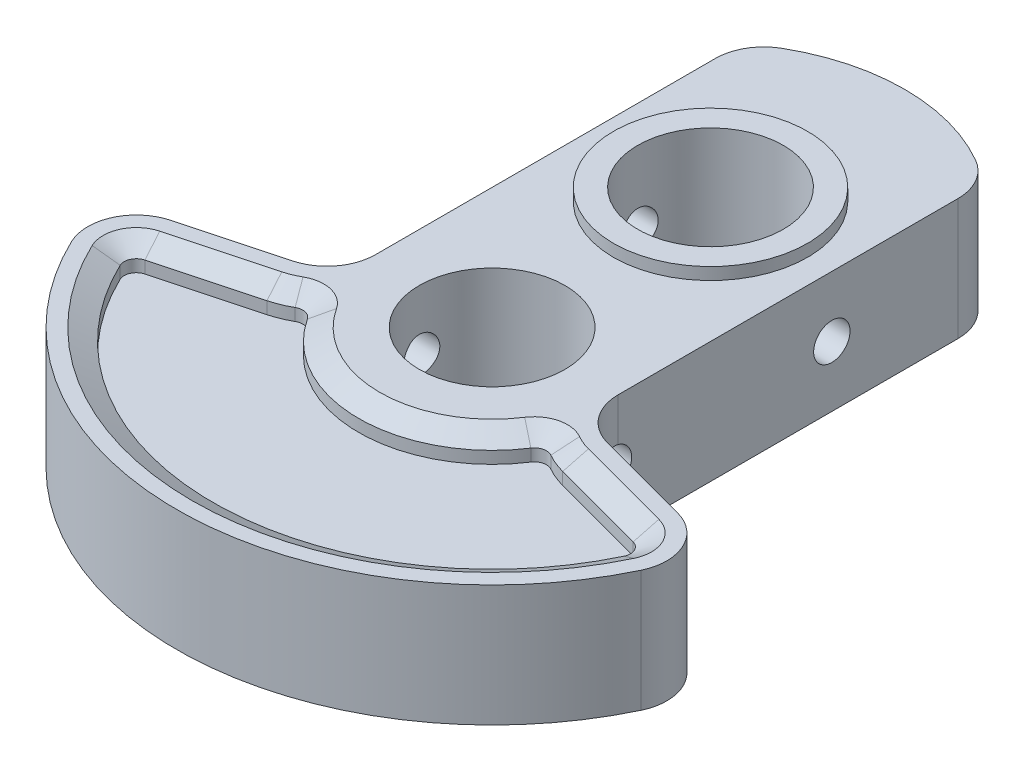
from build123d import *
from OCP.BRepFilletAPI import BRepFilletAPI_MakeChamfer

# Parameters (mm, degrees)
BOSS_EXTRUDE1_DEPTH       = 5
FILLET1_R                 = 4
SKETCH2_R                 = 8
BOSS_EXTRUDE2_DEPTH       = 1
SKETCH3_R                 = 8
BOSS_EXTRUDE3_DEPTH       = 1
SKETCH4_R                 = 6
CUT_EXTRUDE1_DEPTH        = 44.235891121
CUT_EXTRUDE2_DEPTH        = 2
CHAMFER1_SIZE             = 1
CHAMFER1_SIZE2            = 1.732050808
CHAMFER1_OF_MIRROR3_SIZE  = 1
CHAMFER1_OF_MIRROR3_SIZE2 = 1.732050808
SKETCH6_R                 = 1.5
CUT_EXTRUDE3_DEPTH        = 42.968348563
CUT_EXTRUDE3_DEPTH_BACK   = 42.968348563


with BuildPart() as part:
    # Sketch1 → Boss-Extrude1 (new, symmetric)
    with BuildSketch(Plane(origin=(0, 0, 0), x_dir=(1, 0, 0), z_dir=(0, 1, 0))):
        with BuildLine():
            Line((-10, 30.489995997), (-10, -2.679491924))
            Line((-10, -2.679491924), (-25.114071484, -6.729295173))
            ThreePointArc((-25.114071484, -6.729295173), (0, -26), (25.114071484, -6.729295173))
            Line((25.114071484, -6.729295173), (10, -2.679491924))
            Line((10, -2.679491924), (10, 30.489995997))
            ThreePointArc((10, 30.489995997), (0, 34), (-10, 30.489995997))
        make_face()
    extrude(amount=BOSS_EXTRUDE1_DEPTH, both=True)

    # Fillet1
    fillet1_edges = [part.edges().sort_by_distance(p)[0] for p in [
        (10, 0, -30.489995997),
        (10, 0, 2.679491924),
        (25.114071484, 0, 6.729295173),
        (-25.114071484, 0, 6.729295173),
        (-10, 0, 2.679491924),
        (-10, 0, -30.489995997),
    ]]
    fillet(fillet1_edges, radius=FILLET1_R)

    # Sketch2 → Boss-Extrude2 (add)
    with BuildSketch(Plane.XZ.offset(5)):
        with Locations(Location((0, 0, 0), (0, 0, 90))):
            Circle(SKETCH2_R)
    extrude(amount=BOSS_EXTRUDE2_DEPTH)

    # Sketch3 → Boss-Extrude3 (add)
    with BuildSketch(Plane(origin=(0, 5, 0), x_dir=(1, 0, 0), z_dir=(0, 1, 0))):
        with Locations(Location((0, 18, 0), (0, 0, 270))):
            Circle(SKETCH3_R)
    extrude(amount=BOSS_EXTRUDE3_DEPTH)

    # Sketch4 → Cut-Extrude1 (cut, through all)
    with BuildSketch(Plane.XZ.offset(6)):
        with Locations(Location((0, 0, 0), (0, 0, 270))):
            Circle(SKETCH4_R)
        with Locations(Location((0, -18, 0), (0, 0, 270))):
            Circle(SKETCH4_R)
    extrude(amount=-CUT_EXTRUDE1_DEPTH, mode=Mode.SUBTRACT)

    # Sketch5 → Cut-Extrude2 (cut)
    with BuildSketch(Plane(origin=(0, 5, 0), x_dir=(1, 0, 0), z_dir=(0, 1, 0))):
        with BuildLine():
            Line((12.188266684, -6.371664756), (20.119713435, -8.496889508))
            ThreePointArc((20.119713435, -8.496889508), (20.768948696, -9.043962883), (20.763662316, -9.892943304))
            ThreePointArc((20.763662316, -9.892943304), (0, -23), (-20.763662316, -9.892943304))
            ThreePointArc((-20.763662316, -9.892943304), (-20.768948696, -9.043962883), (-20.119713435, -8.496889508))
            Line((-20.119713435, -8.496889508), (-12.188266684, -6.371664756))
            ThreePointArc((-12.188266684, -6.371664756), (-11.342355786, -6.086056673), (-10.539679728, -5.695098402))
            ThreePointArc((-10.539679728, -5.695098402), (-9.810114884, -5.592432974), (-9.208235905, -6.017340901))
            ThreePointArc((-9.208235905, -6.017340901), (0, -11), (9.208235905, -6.017340901))
            ThreePointArc((9.208235905, -6.017340901), (9.810114884, -5.592432974), (10.539679728, -5.695098402))
            ThreePointArc((10.539679728, -5.695098402), (11.342355786, -6.086056673), (12.188266684, -6.371664756))
        make_face()
    cut_extrude2 = extrude(amount=-CUT_EXTRUDE2_DEPTH, mode=Mode.SUBTRACT)

    # Chamfer1: one chamfer whose edges measure the first distance from different faces: ONE call of the kernel's chamfer builder (chamfer() names one face for all edges)
    chamfer1_edges_1 = [part.edges().sort_by_distance(p)[0] for p in [
        (9.810114884, 5, 5.592432974),
    ]]
    chamfer1_side_1 = [part.faces().sort_by_distance(p)[0] for p in [
        (9.810114884, 4, 5.592432974),
    ]]
    chamfer1_edges_2 = [part.edges().sort_by_distance(p)[0] for p in [
        (0, 5, 11),
    ]]
    chamfer1_side_2 = [part.faces().sort_by_distance(p)[0] for p in [
        (0, 4, 11),
    ]]
    chamfer1_edges_3 = [part.edges().sort_by_distance(p)[0] for p in [
        (-9.810114884, 5, 5.592432974),
    ]]
    chamfer1_side_3 = [part.faces().sort_by_distance(p)[0] for p in [
        (-9.810114884, 4, 5.592432974),
    ]]
    chamfer1_edges_4 = [part.edges().sort_by_distance(p)[0] for p in [
        (-11.342355786, 5, 6.086056673),
    ]]
    chamfer1_side_4 = [part.faces().sort_by_distance(p)[0] for p in [
        (-11.342355786, 4, 6.086056673),
    ]]
    chamfer1_edges_5 = [part.edges().sort_by_distance(p)[0] for p in [
        (-16.153990059, 5, 7.434277132),
    ]]
    chamfer1_side_5 = [part.faces().sort_by_distance(p)[0] for p in [
        (-16.153990059, 4, 7.434277132),
    ]]
    chamfer1_edges_6 = [part.edges().sort_by_distance(p)[0] for p in [
        (-20.768948696, 5, 9.043962883),
    ]]
    chamfer1_side_6 = [part.faces().sort_by_distance(p)[0] for p in [
        (-20.768948696, 4, 9.043962883),
    ]]
    chamfer1_edges_7 = [part.edges().sort_by_distance(p)[0] for p in [
        (0, 5, 23),
    ]]
    chamfer1_side_7 = [part.faces().sort_by_distance(p)[0] for p in [
        (0, 4, 23),
    ]]
    chamfer1_edges_8 = [part.edges().sort_by_distance(p)[0] for p in [
        (20.768948696, 5, 9.043962883),
    ]]
    chamfer1_side_8 = [part.faces().sort_by_distance(p)[0] for p in [
        (20.768948696, 4, 9.043962883),
    ]]
    chamfer1_edges_9 = [part.edges().sort_by_distance(p)[0] for p in [
        (16.153990059, 5, 7.434277132),
    ]]
    chamfer1_side_9 = [part.faces().sort_by_distance(p)[0] for p in [
        (16.153990059, 4, 7.434277132),
    ]]
    chamfer1_edges_10 = [part.edges().sort_by_distance(p)[0] for p in [
        (11.342355786, 5, 6.086056673),
    ]]
    chamfer1_side_10 = [part.faces().sort_by_distance(p)[0] for p in [
        (11.342355786, 4, 6.086056673),
    ]]
    chamfer1 = BRepFilletAPI_MakeChamfer(part.part.solid().wrapped)
    for e in chamfer1_edges_1:
        chamfer1.Add(CHAMFER1_SIZE, CHAMFER1_SIZE2, e.wrapped, chamfer1_side_1[0].wrapped)  # the first distance lies on this face
    for e in chamfer1_edges_2:
        chamfer1.Add(CHAMFER1_SIZE, CHAMFER1_SIZE2, e.wrapped, chamfer1_side_2[0].wrapped)  # the first distance lies on this face
    for e in chamfer1_edges_3:
        chamfer1.Add(CHAMFER1_SIZE, CHAMFER1_SIZE2, e.wrapped, chamfer1_side_3[0].wrapped)  # the first distance lies on this face
    for e in chamfer1_edges_4:
        chamfer1.Add(CHAMFER1_SIZE, CHAMFER1_SIZE2, e.wrapped, chamfer1_side_4[0].wrapped)  # the first distance lies on this face
    for e in chamfer1_edges_5:
        chamfer1.Add(CHAMFER1_SIZE, CHAMFER1_SIZE2, e.wrapped, chamfer1_side_5[0].wrapped)  # the first distance lies on this face
    for e in chamfer1_edges_6:
        chamfer1.Add(CHAMFER1_SIZE, CHAMFER1_SIZE2, e.wrapped, chamfer1_side_6[0].wrapped)  # the first distance lies on this face
    for e in chamfer1_edges_7:
        chamfer1.Add(CHAMFER1_SIZE, CHAMFER1_SIZE2, e.wrapped, chamfer1_side_7[0].wrapped)  # the first distance lies on this face
    for e in chamfer1_edges_8:
        chamfer1.Add(CHAMFER1_SIZE, CHAMFER1_SIZE2, e.wrapped, chamfer1_side_8[0].wrapped)  # the first distance lies on this face
    for e in chamfer1_edges_9:
        chamfer1.Add(CHAMFER1_SIZE, CHAMFER1_SIZE2, e.wrapped, chamfer1_side_9[0].wrapped)  # the first distance lies on this face
    for e in chamfer1_edges_10:
        chamfer1.Add(CHAMFER1_SIZE, CHAMFER1_SIZE2, e.wrapped, chamfer1_side_10[0].wrapped)  # the first distance lies on this face
    add(Compound.cast(chamfer1.Shape()), mode=Mode.REPLACE)

    # Mirror3: Cut-Extrude2 across plane
    add(cut_extrude2.mirror(Plane.ZX), mode=Mode.SUBTRACT)

    # Chamfer1 of Mirror3: one chamfer whose edges measure the first distance from different faces: ONE call of the kernel's chamfer builder (chamfer() names one face for all edges)
    chamfer1_of_mirror3_edges_1 = [part.edges().sort_by_distance(p)[0] for p in [
        (9.810114884, -5, 5.592432974),
    ]]
    chamfer1_of_mirror3_side_1 = [part.faces().sort_by_distance(p)[0] for p in [
        (9.810114884, -4, 5.592432974),
    ]]
    chamfer1_of_mirror3_edges_2 = [part.edges().sort_by_distance(p)[0] for p in [
        (0, -5, 11),
    ]]
    chamfer1_of_mirror3_side_2 = [part.faces().sort_by_distance(p)[0] for p in [
        (0, -4, 11),
    ]]
    chamfer1_of_mirror3_edges_3 = [part.edges().sort_by_distance(p)[0] for p in [
        (-9.810114884, -5, 5.592432974),
    ]]
    chamfer1_of_mirror3_side_3 = [part.faces().sort_by_distance(p)[0] for p in [
        (-9.810114884, -4, 5.592432974),
    ]]
    chamfer1_of_mirror3_edges_4 = [part.edges().sort_by_distance(p)[0] for p in [
        (-11.342355786, -5, 6.086056673),
    ]]
    chamfer1_of_mirror3_side_4 = [part.faces().sort_by_distance(p)[0] for p in [
        (-11.342355786, -4, 6.086056673),
    ]]
    chamfer1_of_mirror3_edges_5 = [part.edges().sort_by_distance(p)[0] for p in [
        (-16.153990059, -5, 7.434277132),
    ]]
    chamfer1_of_mirror3_side_5 = [part.faces().sort_by_distance(p)[0] for p in [
        (-16.153990059, -4, 7.434277132),
    ]]
    chamfer1_of_mirror3_edges_6 = [part.edges().sort_by_distance(p)[0] for p in [
        (-20.768948696, -5, 9.043962883),
    ]]
    chamfer1_of_mirror3_side_6 = [part.faces().sort_by_distance(p)[0] for p in [
        (-20.768948696, -4, 9.043962883),
    ]]
    chamfer1_of_mirror3_edges_7 = [part.edges().sort_by_distance(p)[0] for p in [
        (0, -5, 23),
    ]]
    chamfer1_of_mirror3_side_7 = [part.faces().sort_by_distance(p)[0] for p in [
        (0, -4, 23),
    ]]
    chamfer1_of_mirror3_edges_8 = [part.edges().sort_by_distance(p)[0] for p in [
        (20.768948696, -5, 9.043962883),
    ]]
    chamfer1_of_mirror3_side_8 = [part.faces().sort_by_distance(p)[0] for p in [
        (20.768948696, -4, 9.043962883),
    ]]
    chamfer1_of_mirror3_edges_9 = [part.edges().sort_by_distance(p)[0] for p in [
        (16.153990059, -5, 7.434277132),
    ]]
    chamfer1_of_mirror3_side_9 = [part.faces().sort_by_distance(p)[0] for p in [
        (16.153990059, -4, 7.434277132),
    ]]
    chamfer1_of_mirror3_edges_10 = [part.edges().sort_by_distance(p)[0] for p in [
        (11.342355786, -5, 6.086056673),
    ]]
    chamfer1_of_mirror3_side_10 = [part.faces().sort_by_distance(p)[0] for p in [
        (11.342355786, -4, 6.086056673),
    ]]
    chamfer1_of_mirror3 = BRepFilletAPI_MakeChamfer(part.part.solid().wrapped)
    for e in chamfer1_of_mirror3_edges_1:
        chamfer1_of_mirror3.Add(CHAMFER1_OF_MIRROR3_SIZE, CHAMFER1_OF_MIRROR3_SIZE2, e.wrapped, chamfer1_of_mirror3_side_1[0].wrapped)  # the first distance lies on this face
    for e in chamfer1_of_mirror3_edges_2:
        chamfer1_of_mirror3.Add(CHAMFER1_OF_MIRROR3_SIZE, CHAMFER1_OF_MIRROR3_SIZE2, e.wrapped, chamfer1_of_mirror3_side_2[0].wrapped)  # the first distance lies on this face
    for e in chamfer1_of_mirror3_edges_3:
        chamfer1_of_mirror3.Add(CHAMFER1_OF_MIRROR3_SIZE, CHAMFER1_OF_MIRROR3_SIZE2, e.wrapped, chamfer1_of_mirror3_side_3[0].wrapped)  # the first distance lies on this face
    for e in chamfer1_of_mirror3_edges_4:
        chamfer1_of_mirror3.Add(CHAMFER1_OF_MIRROR3_SIZE, CHAMFER1_OF_MIRROR3_SIZE2, e.wrapped, chamfer1_of_mirror3_side_4[0].wrapped)  # the first distance lies on this face
    for e in chamfer1_of_mirror3_edges_5:
        chamfer1_of_mirror3.Add(CHAMFER1_OF_MIRROR3_SIZE, CHAMFER1_OF_MIRROR3_SIZE2, e.wrapped, chamfer1_of_mirror3_side_5[0].wrapped)  # the first distance lies on this face
    for e in chamfer1_of_mirror3_edges_6:
        chamfer1_of_mirror3.Add(CHAMFER1_OF_MIRROR3_SIZE, CHAMFER1_OF_MIRROR3_SIZE2, e.wrapped, chamfer1_of_mirror3_side_6[0].wrapped)  # the first distance lies on this face
    for e in chamfer1_of_mirror3_edges_7:
        chamfer1_of_mirror3.Add(CHAMFER1_OF_MIRROR3_SIZE, CHAMFER1_OF_MIRROR3_SIZE2, e.wrapped, chamfer1_of_mirror3_side_7[0].wrapped)  # the first distance lies on this face
    for e in chamfer1_of_mirror3_edges_8:
        chamfer1_of_mirror3.Add(CHAMFER1_OF_MIRROR3_SIZE, CHAMFER1_OF_MIRROR3_SIZE2, e.wrapped, chamfer1_of_mirror3_side_8[0].wrapped)  # the first distance lies on this face
    for e in chamfer1_of_mirror3_edges_9:
        chamfer1_of_mirror3.Add(CHAMFER1_OF_MIRROR3_SIZE, CHAMFER1_OF_MIRROR3_SIZE2, e.wrapped, chamfer1_of_mirror3_side_9[0].wrapped)  # the first distance lies on this face
    for e in chamfer1_of_mirror3_edges_10:
        chamfer1_of_mirror3.Add(CHAMFER1_OF_MIRROR3_SIZE, CHAMFER1_OF_MIRROR3_SIZE2, e.wrapped, chamfer1_of_mirror3_side_10[0].wrapped)  # the first distance lies on this face
    add(Compound.cast(chamfer1_of_mirror3.Shape()), mode=Mode.REPLACE)

    # Sketch6 → Cut-Extrude3 (cut, two sides)
    with BuildSketch(Plane(origin=(0, 0, 0), x_dir=(0, 0, -1), z_dir=(1, 0, 0))) as cut_extrude3_sk:
        Circle(SKETCH6_R)
        with Locations((18, 0)):
            Circle(SKETCH6_R)
    extrude(amount=CUT_EXTRUDE3_DEPTH, mode=Mode.SUBTRACT)
    extrude(cut_extrude3_sk.sketch, amount=-CUT_EXTRUDE3_DEPTH_BACK, mode=Mode.SUBTRACT)


solid = part.part
